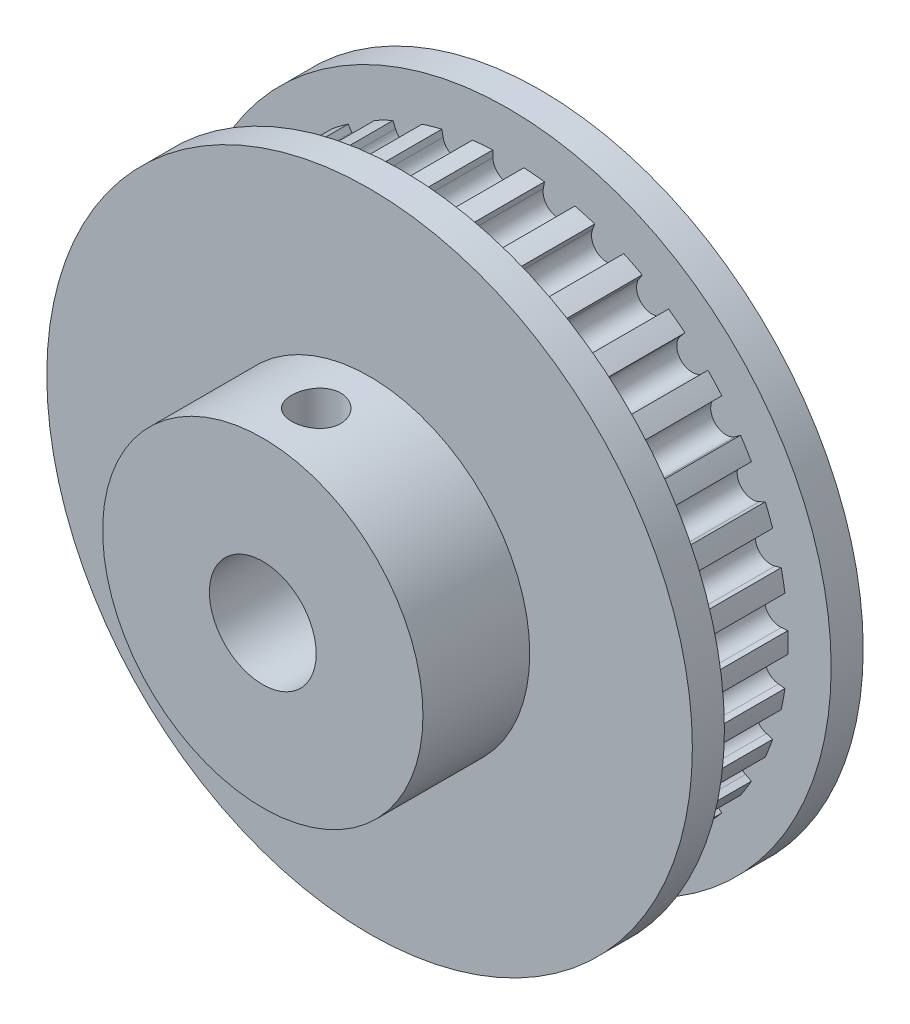
from build123d import *

# Parameters (mm, degrees)
CUT_EXTRUDE1_DEPTH = 10
CIRPATTERN1_COUNT  = 34
SKETCH4_R          = 2.3
CUT_EXTRUDE2_DEPTH = 13


with BuildPart() as part:
    # Sketch2 → Revolve1 (revolve)
    with BuildSketch(Plane(origin=(0, 0, 0), x_dir=(0, 0, -1), z_dir=(1, 0, 0)), mode=Mode.PRIVATE) as revolve1_sk:
        Polygon((-13, 5), (13, 5), (13, 30.23), (10, 30.23), (10, 26.1874), (0, 26.1874), (0, 28.2087), (0, 30.23), (-1.5, 30.23), (-3, 30.23), (-3, 15), (-13, 15), align=None)
    revolve(revolve1_sk.sketch.rotate(Axis((0, 0, 13), (0, 0, -1)), 90), axis=Axis((0, 0, 13), (0, 0, -1)))

    # Sketch3 → Cut-Extrude1 (cut)
    with BuildSketch(Plane.XY):
        with BuildLine():
            Line((-1.447918132, 25.537202459), (-1.45440268, 26.14698131))
            ThreePointArc((-1.45440268, 26.14698131), (0, 26.1874), (1.45440268, 26.14698131))
            Line((1.45440268, 26.14698131), (1.447918132, 25.537202459))
            ThreePointArc((1.447918132, 25.537202459), (0, 24.1046), (-1.447918132, 25.537202459))
        make_face()
    cut_extrude1 = extrude(amount=-CUT_EXTRUDE1_DEPTH, mode=Mode.SUBTRACT)

    # CirPattern1: Cut-Extrude1 ×34 about axis
    cirpattern1_axis = Axis((0, 0, 0), (0, 0, 1))
    for i in range(1, CIRPATTERN1_COUNT):
        add(cut_extrude1.rotate(cirpattern1_axis, i * 360 / CIRPATTERN1_COUNT), mode=Mode.SUBTRACT)

    # Sketch4 → Cut-Extrude2 (cut)
    with BuildSketch(Plane(origin=(0, 15, 0), x_dir=(1, 0, 0), z_dir=(0, 1, 0))):
        with Locations(Location((0, -8, 0), (0, 0, 270))):
            Circle(SKETCH4_R)
    extrude(amount=-CUT_EXTRUDE2_DEPTH, mode=Mode.SUBTRACT)


solid = part.part
